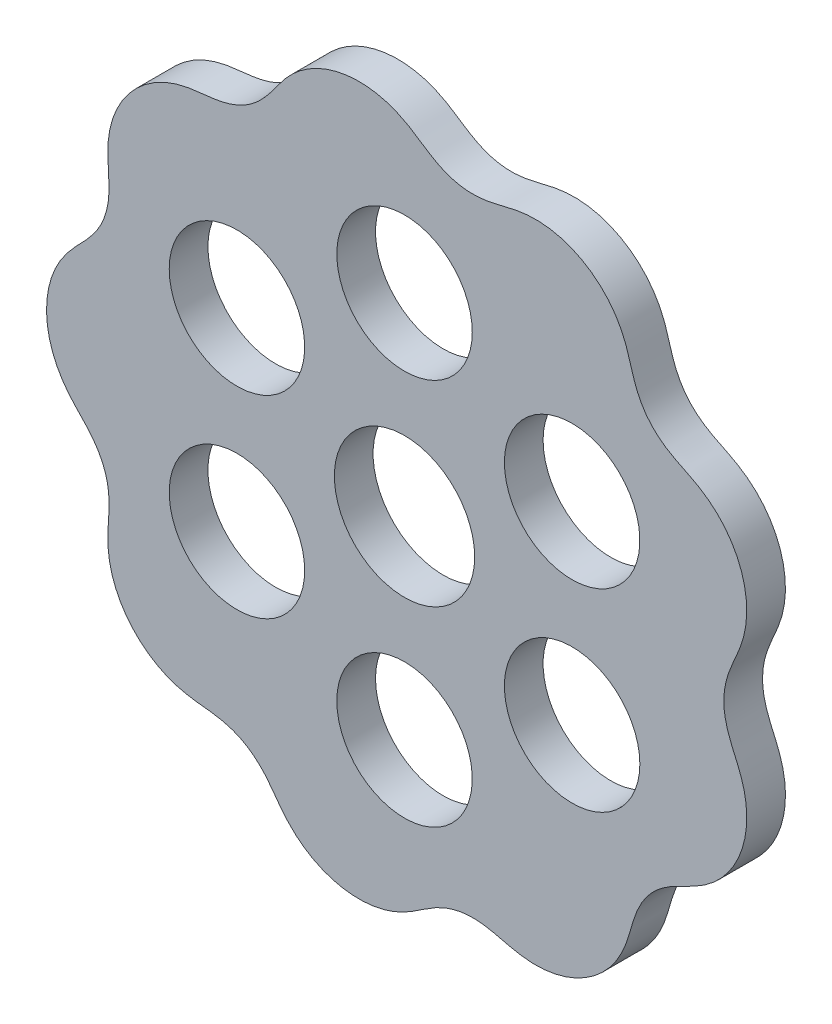
from build123d import *

# Parameters (mm, degrees)
BOSS_EXTRUDE1_DEPTH = 4
SKETCH3_R           = 7.25
CUT_EXTRUDE1_DEPTH  = 5.0000001
SKETCH4_R           = 7
CUT_EXTRUDE2_DEPTH  = 5.0000001
CIRPATTERN1_COUNT   = 6


with BuildPart() as part:
    # Sketch2 → Boss-Extrude1 (new body)
    with BuildSketch(Plane.XY):
        with BuildLine():
            add(Edge.make_bspline(
                [(33, 0), (33, 0.12553263), (33.006279573, 0.375087498), (33.033995401, 0.744846968), (33.078450452, 1.10445872), (33.137301626, 1.450009182), (33.20773948, 1.778739129), (33.286922785, 2.089062185), (33.372108042, 2.380504804), (33.460945471, 2.653467165), (33.551505246, 2.909016093), (33.642358629, 3.148634588), (33.732430922, 3.374068598), (33.821023827, 3.587149736), (33.907743377, 3.789679279), (33.992312739, 3.983430662), (34.074704021, 4.170007212), (34.154889985, 4.350925363), (34.232936694, 4.527528658), (34.30893687, 4.701027986), (34.382963112, 4.872499846), (34.455068419, 5.042906432), (34.525286112, 5.213090427), (34.593669893, 5.383774365), (34.660154697, 5.555616613), (34.724711071, 5.729167426), (34.78725947, 5.904896825), (34.847695164, 6.083213287), (34.905859859, 6.264456032), (34.961616233, 6.448896897), (35.014750379, 6.636767351), (35.065129988, 6.828218141), (35.112455854, 7.023393933), (35.156596015, 7.222343292), (35.197236986, 7.425123872), (35.234212467, 7.631709467), (35.267233912, 7.842071043), (35.296098781, 8.056118446), (35.320560731, 8.273747716), (35.340390552, 8.494814823), (35.355373574, 8.71914917), (35.365276709, 8.946558303), (35.369937718, 9.176820248), (35.369158767, 9.409695994), (35.362756857, 9.644921482), (35.350585299, 9.88221279), (35.332516501, 10.121280153), (35.30842634, 10.361808964), (35.278232355, 10.603480997), (35.241833438, 10.845956178), (35.199188137, 11.088899173), (35.150265015, 11.331959673), (35.095051004, 11.574786653), (35.033560116, 11.817023046), (34.965831637, 12.058316911), (34.89191067, 12.298311182), (34.811884594, 12.536657353), (34.725857402, 12.773012048), (34.633953155, 13.00703529), (34.536310687, 13.238394865), (34.433093942, 13.466773568), (34.324495961, 13.691865676), (34.210705098, 13.913372069), (34.091939112, 14.131010174), (33.968455375, 14.344530164), (33.840470585, 14.553668884), (33.708271364, 14.758217258), (33.572111879, 14.957953832), (33.432289899, 15.152709281), (33.28907516, 15.342302656), (33.142787006, 15.526615816), (32.993698434, 15.705513714), (32.842111494, 15.878902733), (32.688343005, 16.046737563), (32.532666931, 16.208957117), (32.375385617, 16.365566111), (32.216750424, 16.516548186), (32.057057619, 16.661974127), (31.89653629, 16.801884368), (31.73543292, 16.936383957), (31.573939877, 17.065574474), (31.412261582, 17.189628466), (31.25054194, 17.308708169), (31.08889597, 17.422997718), (30.927419369, 17.532743893), (30.7661561, 17.638205423), (30.605088205, 17.739645698), (30.444180041, 17.837405815), (30.283308185, 17.931819921), (30.122299104, 18.023269876), (29.960901455, 18.112161171), (29.79881075, 18.198969559), (29.635630397, 18.284206387), (29.470853606, 18.368379717), (29.303935278, 18.452171813), (29.134194665, 18.536226506), (28.96088611, 18.621344015), (28.783165292, 18.708381454), (28.600119766, 18.79835495), (28.410790633, 18.892406287), (28.214184873, 18.991828679), (28.009354406, 19.098102885), (27.795446663, 19.212893376), (27.571827908, 19.338058027), (27.338184991, 19.475602167), (27.094681821, 19.627609979), (26.842080553, 19.796098363), (26.581960792, 19.982936284), (26.316687995, 20.189467086), (26.04950029, 20.416355724), (25.78429141, 20.663258736), (25.52536734, 20.928681193), (25.27705575, 21.209966466), (25.043165446, 21.503351617), (24.82673082, 21.80443266), (24.62963072, 22.108484781), (24.452592408, 22.411019433), (24.295267263, 22.708123318), (24.156428544, 22.996734281), (24.034357478, 23.274749934), (23.92695169, 23.540955636), (23.832070987, 23.794931778), (23.747644698, 24.036888514), (23.671729145, 24.2674739), (23.602640108, 24.487650641), (23.538874232, 24.698537028), (23.479122238, 24.901320218), (23.422302364, 25.097205885), (23.367446548, 25.287342212), (23.313717452, 25.472796692), (23.260420936, 25.654557765), (23.206885664, 25.833488311), (23.152589274, 26.010376316), (23.097006271, 26.185884405), (23.039656754, 26.360585955), (22.980137739, 26.534966659), (22.918035808, 26.709409848), (22.85299235, 26.884232657), (22.784666989, 27.059673083), (22.712728622, 27.235906158), (22.636874162, 27.413033728), (22.556828501, 27.591109374), (22.472346263, 27.770143328), (22.383167271, 27.950087988), (22.289067228, 28.130851667), (22.18988343, 28.312331132), (22.085397272, 28.494339673), (21.975484654, 28.676716952), (21.860003652, 28.859238678), (21.738861055, 29.041678771), (21.611949853, 29.223770397), (21.479217881, 29.405241744), (21.34064873, 29.585831104), (21.196194455, 29.765206451), (21.04591332, 29.943105604), (20.88980923, 30.119179728), (20.727958651, 30.2931342), (20.560457769, 30.464662672), (20.387381765, 30.63342261), (20.208907804, 30.799144934), (20.025162875, 30.961498728), (19.836331685, 31.120191089), (19.642617356, 31.274938707), (19.444239603, 31.425464396), (19.24142684, 31.571500563), (19.034445368, 31.712806876), (18.823551595, 31.849137851), (18.609039053, 31.980279893), (18.391220098, 32.106054467), (18.170386866, 32.226243578), (17.946876072, 32.340719194), (17.721007109, 32.449317332), (17.493124574, 32.55193535), (17.263579357, 32.648478684), (17.032707701, 32.738873521), (16.800858484, 32.823042778), (16.568387013, 32.901001626), (16.335633408, 32.97270696), (16.102942132, 33.038206873), (15.870643449, 33.097505335), (15.639069555, 33.150694223), (15.408532012, 33.197837488), (15.179332611, 33.239059322), (14.951756992, 33.274455601), (14.726077141, 33.304171029), (14.50255218, 33.328383285), (14.28140279, 33.347241549), (14.062833672, 33.360937608), (13.847025657, 33.369683198), (13.634125034, 33.373697441), (13.424255309, 33.373152663), (13.217496676, 33.368331289), (13.013903121, 33.359426633), (12.813476772, 33.346698289), (12.616186384, 33.330347373), (12.421943643, 33.310626137), (12.230622713, 33.287749814), (12.042034408, 33.2619321), (11.855932295, 33.233395934), (11.672012527, 33.202300034), (11.489888098, 33.168863239), (11.309110788, 33.133221808), (11.12914045, 33.095525486), (10.949345622, 33.055924648), (10.769010509, 33.014493655), (10.587284669, 32.97139432), (10.403229236, 32.926672768), (10.215758299, 32.880474695), (10.023670132, 32.832907525), (9.825614052, 32.784190326), (9.620127588, 32.734519364), (9.405606899, 32.684318233), (9.180385781, 32.634055683), (8.942734121, 32.584508441), (8.690978854, 32.536640286), (8.423585585, 32.491820928), (8.139344037, 32.451732608), (7.837537509, 32.418462803), (7.518178574, 32.394370937), (7.182212158, 32.382069794), (6.831692591, 32.384124453), (6.469825315, 32.40279581), (6.100868235, 32.43969735), (5.729842354, 32.495554234), (5.362091269, 32.569970638), (5.002760027, 32.661475745), (4.656333738, 32.767708885), (4.326244593, 32.885655402), (4.014748663, 33.01212546), (3.722884215, 33.143982767), (3.450657043, 33.278471346), (3.197274119, 33.413363502), (2.961342887, 33.546938013), (2.741132669, 33.678005347), (2.534769756, 33.805863036), (2.340313653, 33.930113691), (2.155916926, 34.050679582), (1.97978911, 34.167605507), (1.81035742, 34.281153561), (1.64610722, 34.391530254), (1.485746686, 34.499067795), (1.328073849, 34.604025321), (1.172070856, 34.706711316), (1.0167655, 34.807297479), (0.861366885, 34.90601385), (0.705141565, 35.002988745), (0.547462441, 35.098316157), (0.387753578, 35.192018731), (0.225562033, 35.284145775), (0.060435418, 35.37460401), (-0.107944759, 35.463373103), (-0.27990324, 35.550307585), (-0.455686718, 35.635268929), (-0.635493509, 35.718099436), (-0.819468078, 35.798638174), (-1.007747803, 35.876617361), (-1.200380981, 35.951880493), (-1.397413404, 36.024159743), (-1.598840637, 36.093218833), (-1.804627734, 36.158797214), (-2.014699665, 36.220685281), (-2.228962735, 36.278602556), (-2.447293199, 36.332298816), (-2.669522355, 36.381554777), (-2.895478825, 36.426133844), (-3.12495136, 36.465795293), (-3.357713281, 36.500342206), (-3.593512378, 36.529568098), (-3.832085586, 36.553280072), (-4.073144064, 36.571330415), (-4.316389504, 36.583540636), (-4.561503139, 36.58981522), (-4.808159179, 36.589997725), (-5.05602004, 36.584030666), (-5.304745639, 36.571821792), (-5.55398056, 36.553317168), (-5.803372228, 36.528530698), (-6.05255323, 36.497395416), (-6.301176621, 36.459985103), (-6.548878869, 36.416313902), (-6.795306375, 36.36644189), (-7.040103302, 36.310448217), (-7.282937638, 36.248460906), (-7.523468116, 36.180592058), (-7.761369437, 36.106995698), (-7.996327399, 36.027837009), (-8.228045687, 35.943306116), (-8.456228068, 35.853574638), (-8.680624402, 35.758902333), (-8.900969343, 35.659493323), (-9.117051337, 35.555624685), (-9.328630414, 35.447502553), (-9.53554474, 35.335437686), (-9.737614247, 35.219680536), (-9.934696507, 35.10051126), (-10.126676072, 34.978216112), (-10.313469587, 34.85308499), (-10.495003377, 34.725374798), (-10.671246701, 34.595376714), (-10.842191396, 34.463362613), (-11.007848927, 34.329578741), (-11.168279118, 34.194277415), (-11.323553437, 34.057668157), (-11.473801436, 33.91998689), (-11.619147449, 33.781392469), (-11.759780224, 33.642058178), (-11.895892682, 33.502086963), (-12.027748191, 33.36158237), (-12.155627851, 33.220588347), (-12.279843512, 33.079100443), (-12.40074852, 32.937060716), (-12.518775983, 32.794387337), (-12.634348443, 32.65088173), (-12.747982513, 32.506321904), (-12.860248078, 32.360409923), (-12.971768683, 32.212758831), (-13.083258312, 32.062921411), (-13.195524915, 31.910366036), (-13.309434405, 31.754465831), (-13.426015888, 31.59456092), (-13.546405432, 31.429919557), (-13.671913564, 31.259804349), (-13.80395207, 31.083438316), (-13.944195046, 30.900184725), (-14.09437861, 30.709454235), (-14.256474792, 30.510968142), (-14.432500811, 30.304757556), (-14.624473994, 30.091342224), (-14.834275827, 29.871846128), (-15.063442767, 29.648121291), (-15.312902911, 29.422748519), (-15.582734339, 29.199013838), (-15.87193629, 28.980703292), (-16.17830184, 28.771819444), (-16.498423318, 28.576106746), (-16.82797235, 28.396724854), (-17.162062224, 28.235864855), (-17.495716123, 28.094543466), (-17.824398986, 27.972738936), (-18.144306853, 27.869379129), (-18.452646045, 27.78278676), (-18.747634224, 27.71083948), (-19.028440133, 27.651283907), (-19.295037502, 27.601965904), (-19.54797623, 27.560811344), (-19.788246142, 27.52611313), (-20.017074741, 27.496304675), (-20.235826902, 27.470113207), (-20.445909806, 27.446501966), (-20.648683422, 27.424542518), (-20.845458218, 27.403547622), (-21.03742371, 27.382834469), (-21.225676907, 27.361906237), (-21.411186158, 27.340267622), (-21.594814861, 27.317512716), (-21.777309428, 27.29322938), (-21.95931799, 27.26711177), (-22.141382271, 27.238764203), (-22.323958694, 27.207903506), (-22.507421011, 27.174204157), (-22.692062096, 27.137381162), (-22.878102525, 27.097123208), (-23.065712958, 27.053198338), (-23.254986675, 27.005295249), (-23.445974561, 26.953173435), (-23.638667212, 26.896587351), (-23.833030141, 26.83533155), (-24.028963534, 26.769142066), (-24.226360386, 26.697865852), (-24.425057113, 26.62129727), (-24.624854807, 26.539253666), (-24.825558886, 26.451626762), (-25.026925123, 26.35827691), (-25.228683958, 26.259059679), (-25.430589419, 26.153954726), (-25.632335336, 26.042862107), (-25.833615294, 25.92574142), (-26.0341193, 25.802581057), (-26.233543124, 25.673406958), (-26.431541153, 25.53821912), (-26.62781068, 25.397099826), (-26.82199596, 25.250097064), (-27.013789417, 25.097337777), (-27.202861558, 24.938940242), (-27.3888961, 24.775041633), (-27.571577712, 24.605807751), (-27.750630187, 24.431449774), (-27.92571202, 24.252126909), (-28.09660786, 24.068126528), (-28.263012325, 23.879651592), (-28.424686188, 23.686973372), (-28.581397278, 23.490364625), (-28.732947845, 23.290127749), (-28.879122884, 23.086552287), (-29.019752326, 22.879954138), (-29.154682091, 22.670656575), (-29.283784708, 22.458988338), (-29.406948786, 22.245282024), (-29.524077695, 22.029873164), (-29.635134786, 21.813115696), (-29.740020278, 21.595323651), (-29.838780023, 21.376860898), (-29.931367136, 21.158035901), (-30.017828311, 20.93918341), (-30.09820864, 20.720620565), (-30.172603668, 20.502657172), (-30.241051484, 20.285566096), (-30.303699396, 20.069633832), (-30.36067499, 19.855117517), (-30.412140336, 19.642254736), (-30.458211434, 19.431240916), (-30.499120739, 19.222275113), (-30.53505128, 19.015502984), (-30.566197587, 18.811050125), (-30.592780242, 18.60900071), (-30.61504895, 18.409407417), (-30.633211587, 18.212270482), (-30.647506651, 18.017554056), (-30.658204539, 17.825166523), (-30.665543328, 17.634960056), (-30.669731076, 17.446727481), (-30.671072772, 17.260203406), (-30.669755693, 17.075043574), (-30.666040016, 16.890825451), (-30.66019299, 16.707044113), (-30.652382952, 16.523105571), (-30.642924718, 16.33831319), (-30.63201537, 16.151862591), (-30.619932186, 15.962836648), (-30.607000474, 15.770189413), (-30.593515421, 15.57275999), (-30.579917187, 15.36925468), (-30.566699455, 15.158265515), (-30.554493573, 14.938289101), (-30.54411994, 14.707759292), (-30.536582795, 14.465115689), (-30.533174557, 14.208873681), (-30.535454116, 13.937762288), (-30.545340477, 13.650875497), (-30.564962781, 13.347874511), (-30.596719402, 13.029186169), (-30.64293677, 12.696190041), (-30.705826297, 12.351349844), (-30.78705942, 11.998222902), (-30.887454754, 11.64127175), (-31.006897874, 11.285586148), (-31.144034446, 10.936340178), (-31.296557294, 10.598364954), (-31.461333004, 10.275646955), (-31.63480283, 9.971055392), (-31.813445486, 9.686256078), (-31.993969112, 9.42171803), (-32.17370262, 9.176990397), (-32.350529956, 8.950866823), (-32.523055742, 8.741721436), (-32.690365723, 8.547613155), (-32.852118238, 8.366589329), (-33.008244645, 8.196659853), (-33.159000039, 8.036000641), (-33.304741669, 7.882862299), (-33.445970247, 7.735707717), (-33.583203224, 7.593130406), (-33.716949226, 7.453876246), (-33.847704279, 7.316835707), (-33.975905062, 7.181017676), (-34.101939416, 7.045542693), (-34.226137486, 6.909643577), (-34.348775456, 6.772640813), (-34.470013858, 6.633892904), (-34.59004643, 6.49289732), (-34.708927798, 6.349156045), (-34.826701065, 6.202260425), (-34.943348705, 6.051843675), (-35.058819863, 5.897591268), (-35.17302367, 5.739234906), (-35.285824067, 5.576547056), (-35.397071647, 5.409342815), (-35.506572671, 5.23747215), (-35.614132546, 5.060831117), (-35.719531849, 4.87935002), (-35.822504679, 4.692967606), (-35.922840602, 4.501699623), (-36.020264628, 4.305562058), (-36.11449737, 4.104605054), (-36.205308381, 3.898928797), (-36.292400789, 3.688626935), (-36.375532514, 3.473846033), (-36.454447511, 3.254748979), (-36.528871497, 3.03151718), (-36.598609902, 2.804376675), (-36.663383603, 2.573543825), (-36.723014665, 2.339281009), (-36.777303065, 2.101857519), (-36.826013865, 1.861549948), (-36.869040999, 1.618675413), (-36.906206293, 1.373540455), (-36.937366471, 1.126474948), (-36.962429457, 0.877815117), (-36.981323653, 0.627911778), (-36.99393153, 0.377105433), (-37.00026675, 0.125763276), (-37.00026675, -0.125763276), (-36.99393153, -0.377105433), (-36.981323653, -0.627911778), (-36.962429457, -0.877815117), (-36.937366471, -1.126474948), (-36.906206293, -1.373540455), (-36.869040999, -1.618675413), (-36.826013865, -1.861549948), (-36.777303065, -2.101857519), (-36.723014665, -2.339281009), (-36.663383603, -2.573543825), (-36.598609902, -2.804376675), (-36.528871497, -3.03151718), (-36.454447511, -3.254748979), (-36.375532514, -3.473846033), (-36.292400789, -3.688626935), (-36.205308381, -3.898928797), (-36.11449737, -4.104605054), (-36.020264628, -4.305562058), (-35.922840602, -4.501699623), (-35.822504679, -4.692967606), (-35.719531849, -4.87935002), (-35.614132546, -5.060831117), (-35.506572671, -5.23747215), (-35.397071647, -5.409342815), (-35.285824067, -5.576547056), (-35.17302367, -5.739234906), (-35.058819863, -5.897591268), (-34.943348705, -6.051843675), (-34.826701065, -6.202260425), (-34.708927798, -6.349156045), (-34.59004643, -6.49289732), (-34.470013858, -6.633892904), (-34.348775456, -6.772640813), (-34.226137486, -6.909643577), (-34.101939416, -7.045542693), (-33.975905062, -7.181017676), (-33.847704279, -7.316835707), (-33.716949226, -7.453876246), (-33.583203224, -7.593130406), (-33.445970247, -7.735707717), (-33.304741669, -7.882862299), (-33.159000039, -8.036000641), (-33.008244645, -8.196659853), (-32.852118238, -8.366589329), (-32.690365723, -8.547613155), (-32.523055742, -8.741721436), (-32.350529956, -8.950866823), (-32.17370262, -9.176990397), (-31.993969112, -9.42171803), (-31.813445486, -9.686256078), (-31.63480283, -9.971055392), (-31.461333004, -10.275646955), (-31.296557294, -10.598364954), (-31.144034446, -10.936340178), (-31.006897874, -11.285586148), (-30.887454754, -11.64127175), (-30.78705942, -11.998222902), (-30.705826297, -12.351349844), (-30.64293677, -12.696190041), (-30.596719402, -13.029186169), (-30.564962781, -13.347874511), (-30.545340477, -13.650875497), (-30.535454116, -13.937762288), (-30.533174557, -14.208873681), (-30.536582795, -14.465115689), (-30.54411994, -14.707759292), (-30.554493573, -14.938289101), (-30.566699455, -15.158265515), (-30.579917187, -15.36925468), (-30.593515421, -15.57275999), (-30.607000474, -15.770189413), (-30.619932186, -15.962836648), (-30.63201537, -16.151862591), (-30.642924718, -16.33831319), (-30.652382952, -16.523105571), (-30.66019299, -16.707044113), (-30.666040016, -16.890825451), (-30.669755693, -17.075043574), (-30.671072772, -17.260203406), (-30.669731076, -17.446727481), (-30.665543328, -17.634960056), (-30.658204539, -17.825166523), (-30.647506651, -18.017554056), (-30.633211587, -18.212270482), (-30.61504895, -18.409407417), (-30.592780242, -18.60900071), (-30.566197587, -18.811050125), (-30.53505128, -19.015502984), (-30.499120739, -19.222275113), (-30.458211434, -19.431240916), (-30.412140336, -19.642254736), (-30.36067499, -19.855117517), (-30.303699396, -20.069633832), (-30.241051484, -20.285566096), (-30.172603668, -20.502657172), (-30.09820864, -20.720620565), (-30.017828311, -20.93918341), (-29.931367136, -21.158035901), (-29.838780023, -21.376860898), (-29.740020278, -21.595323651), (-29.635134786, -21.813115696), (-29.524077695, -22.029873164), (-29.406948786, -22.245282024), (-29.283784708, -22.458988338), (-29.154682091, -22.670656575), (-29.019752326, -22.879954138), (-28.879122884, -23.086552287), (-28.732947845, -23.290127749), (-28.581397278, -23.490364625), (-28.424686188, -23.686973372), (-28.263012325, -23.879651592), (-28.09660786, -24.068126528), (-27.92571202, -24.252126909), (-27.750630187, -24.431449774), (-27.571577712, -24.605807751), (-27.3888961, -24.775041633), (-27.202861558, -24.938940242), (-27.013789417, -25.097337777), (-26.82199596, -25.250097064), (-26.62781068, -25.397099826), (-26.431541153, -25.53821912), (-26.233543124, -25.673406958), (-26.0341193, -25.802581057), (-25.833615294, -25.92574142), (-25.632335336, -26.042862107), (-25.430589419, -26.153954726), (-25.228683958, -26.259059679), (-25.026925123, -26.35827691), (-24.825558886, -26.451626762), (-24.624854807, -26.539253666), (-24.425057113, -26.62129727), (-24.226360386, -26.697865852), (-24.028963534, -26.769142066), (-23.833030141, -26.83533155), (-23.638667212, -26.896587351), (-23.445974561, -26.953173435), (-23.254986675, -27.005295249), (-23.065712958, -27.053198338), (-22.878102525, -27.097123208), (-22.692062096, -27.137381162), (-22.507421011, -27.174204157), (-22.323958694, -27.207903506), (-22.141382271, -27.238764203), (-21.95931799, -27.26711177), (-21.777309428, -27.29322938), (-21.594814861, -27.317512716), (-21.411186158, -27.340267622), (-21.225676907, -27.361906237), (-21.03742371, -27.382834469), (-20.845458218, -27.403547622), (-20.648683422, -27.424542518), (-20.445909806, -27.446501966), (-20.235826902, -27.470113207), (-20.017074741, -27.496304675), (-19.788246142, -27.52611313), (-19.54797623, -27.560811344), (-19.295037502, -27.601965904), (-19.028440133, -27.651283907), (-18.747634224, -27.71083948), (-18.452646045, -27.78278676), (-18.144306853, -27.869379129), (-17.824398986, -27.972738936), (-17.495716123, -28.094543466), (-17.162062224, -28.235864855), (-16.82797235, -28.396724854), (-16.498423318, -28.576106746), (-16.17830184, -28.771819444), (-15.87193629, -28.980703292), (-15.582734339, -29.199013838), (-15.312902911, -29.422748519), (-15.063442767, -29.648121291), (-14.834275827, -29.871846128), (-14.624473994, -30.091342224), (-14.432500811, -30.304757556), (-14.256474792, -30.510968142), (-14.09437861, -30.709454235), (-13.944195046, -30.900184725), (-13.80395207, -31.083438316), (-13.671913564, -31.259804349), (-13.546405432, -31.429919557), (-13.426015888, -31.59456092), (-13.309434405, -31.754465831), (-13.195524915, -31.910366036), (-13.083258312, -32.062921411), (-12.971768683, -32.212758831), (-12.860248078, -32.360409923), (-12.747982513, -32.506321904), (-12.634348443, -32.65088173), (-12.518775983, -32.794387337), (-12.40074852, -32.937060716), (-12.279843512, -33.079100443), (-12.155627851, -33.220588347), (-12.027748191, -33.36158237), (-11.895892682, -33.502086963), (-11.759780224, -33.642058178), (-11.619147449, -33.781392469), (-11.473801436, -33.91998689), (-11.323553437, -34.057668157), (-11.168279118, -34.194277415), (-11.007848927, -34.329578741), (-10.842191396, -34.463362613), (-10.671246701, -34.595376714), (-10.495003377, -34.725374798), (-10.313469587, -34.85308499), (-10.126676072, -34.978216112), (-9.934696507, -35.10051126), (-9.737614247, -35.219680536), (-9.53554474, -35.335437686), (-9.328630414, -35.447502553), (-9.117051337, -35.555624685), (-8.900969343, -35.659493323), (-8.680624402, -35.758902333), (-8.456228068, -35.853574638), (-8.228045687, -35.943306116), (-7.996327399, -36.027837009), (-7.761369437, -36.106995698), (-7.523468116, -36.180592058), (-7.282937638, -36.248460906), (-7.040103302, -36.310448217), (-6.795306375, -36.36644189), (-6.548878869, -36.416313902), (-6.301176621, -36.459985103), (-6.05255323, -36.497395416), (-5.803372228, -36.528530698), (-5.55398056, -36.553317168), (-5.304745639, -36.571821792), (-5.05602004, -36.584030666), (-4.808159179, -36.589997725), (-4.561503139, -36.58981522), (-4.316389504, -36.583540636), (-4.073144064, -36.571330415), (-3.832085586, -36.553280072), (-3.593512378, -36.529568098), (-3.357713281, -36.500342206), (-3.12495136, -36.465795293), (-2.895478825, -36.426133844), (-2.669522355, -36.381554777), (-2.447293199, -36.332298816), (-2.228962735, -36.278602556), (-2.014699665, -36.220685281), (-1.804627734, -36.158797214), (-1.598840637, -36.093218833), (-1.397413404, -36.024159743), (-1.200380981, -35.951880493), (-1.007747803, -35.876617361), (-0.819468078, -35.798638174), (-0.635493509, -35.718099436), (-0.455686718, -35.635268929), (-0.27990324, -35.550307585), (-0.107944759, -35.463373103), (0.060435418, -35.37460401), (0.225562033, -35.284145775), (0.387753578, -35.192018731), (0.547462441, -35.098316157), (0.705141565, -35.002988745), (0.861366885, -34.90601385), (1.0167655, -34.807297479), (1.172070856, -34.706711316), (1.328073849, -34.604025321), (1.485746686, -34.499067795), (1.64610722, -34.391530254), (1.81035742, -34.281153561), (1.97978911, -34.167605507), (2.155916926, -34.050679582), (2.340313653, -33.930113691), (2.534769756, -33.805863036), (2.741132669, -33.678005347), (2.961342887, -33.546938013), (3.197274119, -33.413363502), (3.450657043, -33.278471346), (3.722884215, -33.143982767), (4.014748663, -33.01212546), (4.326244593, -32.885655402), (4.656333738, -32.767708885), (5.002760027, -32.661475745), (5.362091269, -32.569970638), (5.729842354, -32.495554234), (6.100868235, -32.43969735), (6.469825315, -32.40279581), (6.831692591, -32.384124453), (7.182212158, -32.382069794), (7.518178574, -32.394370937), (7.837537509, -32.418462803), (8.139344037, -32.451732608), (8.423585585, -32.491820928), (8.690978854, -32.536640286), (8.942734121, -32.584508441), (9.180385781, -32.634055683), (9.405606899, -32.684318233), (9.620127588, -32.734519364), (9.825614052, -32.784190326), (10.023670132, -32.832907525), (10.215758299, -32.880474695), (10.403229236, -32.926672768), (10.587284669, -32.97139432), (10.769010509, -33.014493655), (10.949345622, -33.055924648), (11.12914045, -33.095525486), (11.309110788, -33.133221808), (11.489888098, -33.168863239), (11.672012527, -33.202300034), (11.855932295, -33.233395934), (12.042034408, -33.2619321), (12.230622713, -33.287749814), (12.421943643, -33.310626137), (12.616186384, -33.330347373), (12.813476772, -33.346698289), (13.013903121, -33.359426633), (13.217496676, -33.368331289), (13.424255309, -33.373152663), (13.634125034, -33.373697441), (13.847025657, -33.369683198), (14.062833672, -33.360937608), (14.28140279, -33.347241549), (14.50255218, -33.328383285), (14.726077141, -33.304171029), (14.951756992, -33.274455601), (15.179332611, -33.239059322), (15.408532012, -33.197837488), (15.639069555, -33.150694223), (15.870643449, -33.097505335), (16.102942132, -33.038206873), (16.335633408, -32.97270696), (16.568387013, -32.901001626), (16.800858484, -32.823042778), (17.032707701, -32.738873521), (17.263579357, -32.648478684), (17.493124574, -32.55193535), (17.721007109, -32.449317332), (17.946876072, -32.340719194), (18.170386866, -32.226243578), (18.391220098, -32.106054467), (18.609039053, -31.980279893), (18.823551595, -31.849137851), (19.034445368, -31.712806876), (19.24142684, -31.571500563), (19.444239603, -31.425464396), (19.642617356, -31.274938707), (19.836331685, -31.120191089), (20.025162875, -30.961498728), (20.208907804, -30.799144934), (20.387381765, -30.63342261), (20.560457769, -30.464662672), (20.727958651, -30.2931342), (20.88980923, -30.119179728), (21.04591332, -29.943105604), (21.196194455, -29.765206451), (21.34064873, -29.585831104), (21.479217881, -29.405241744), (21.611949853, -29.223770397), (21.738861055, -29.041678771), (21.860003652, -28.859238678), (21.975484654, -28.676716952), (22.085397272, -28.494339673), (22.18988343, -28.312331132), (22.289067228, -28.130851667), (22.383167271, -27.950087988), (22.472346263, -27.770143328), (22.556828501, -27.591109374), (22.636874162, -27.413033728), (22.712728622, -27.235906158), (22.784666989, -27.059673083), (22.85299235, -26.884232657), (22.918035808, -26.709409848), (22.980137739, -26.534966659), (23.039656754, -26.360585955), (23.097006271, -26.185884405), (23.152589274, -26.010376316), (23.206885664, -25.833488311), (23.260420936, -25.654557765), (23.313717452, -25.472796692), (23.367446548, -25.287342212), (23.422302364, -25.097205885), (23.479122238, -24.901320218), (23.538874232, -24.698537028), (23.602640108, -24.487650641), (23.671729145, -24.2674739), (23.747644698, -24.036888514), (23.832070987, -23.794931778), (23.92695169, -23.540955636), (24.034357478, -23.274749934), (24.156428544, -22.996734281), (24.295267263, -22.708123318), (24.452592408, -22.411019433), (24.62963072, -22.108484781), (24.82673082, -21.80443266), (25.043165446, -21.503351617), (25.27705575, -21.209966466), (25.52536734, -20.928681193), (25.78429141, -20.663258736), (26.04950029, -20.416355724), (26.316687995, -20.189467086), (26.581960792, -19.982936284), (26.842080553, -19.796098363), (27.094681821, -19.627609979), (27.338184991, -19.475602167), (27.571827908, -19.338058027), (27.795446663, -19.212893376), (28.009354406, -19.098102885), (28.214184873, -18.991828679), (28.410790633, -18.892406287), (28.600119766, -18.79835495), (28.783165292, -18.708381454), (28.96088611, -18.621344015), (29.134194665, -18.536226506), (29.303935278, -18.452171813), (29.470853606, -18.368379717), (29.635630397, -18.284206387), (29.79881075, -18.198969559), (29.960901455, -18.112161171), (30.122299104, -18.023269876), (30.283308185, -17.931819921), (30.444180041, -17.837405815), (30.605088205, -17.739645698), (30.7661561, -17.638205423), (30.927419369, -17.532743893), (31.08889597, -17.422997718), (31.25054194, -17.308708169), (31.412261582, -17.189628466), (31.573939877, -17.065574474), (31.73543292, -16.936383957), (31.89653629, -16.801884368), (32.057057619, -16.661974127), (32.216750424, -16.516548186), (32.375385617, -16.365566111), (32.532666931, -16.208957117), (32.688343005, -16.046737563), (32.842111494, -15.878902733), (32.993698434, -15.705513714), (33.142787006, -15.526615816), (33.28907516, -15.342302656), (33.432289899, -15.152709281), (33.572111879, -14.957953832), (33.708271364, -14.758217258), (33.840470585, -14.553668884), (33.968455375, -14.344530164), (34.091939112, -14.131010174), (34.210705098, -13.913372069), (34.324495961, -13.691865676), (34.433093942, -13.466773568), (34.536310687, -13.238394865), (34.633953155, -13.00703529), (34.725857402, -12.773012048), (34.811884594, -12.536657353), (34.89191067, -12.298311182), (34.965831637, -12.058316911), (35.033560116, -11.817023046), (35.095051004, -11.574786653), (35.150265015, -11.331959673), (35.199188137, -11.088899173), (35.241833438, -10.845956178), (35.278232355, -10.603480997), (35.30842634, -10.361808964), (35.332516501, -10.121280153), (35.350585299, -9.88221279), (35.362756857, -9.644921482), (35.369158767, -9.409695994), (35.369937718, -9.176820248), (35.365276709, -8.946558303), (35.355373574, -8.71914917), (35.340390552, -8.494814823), (35.320560731, -8.273747716), (35.296098781, -8.056118446), (35.267233912, -7.842071043), (35.234212467, -7.631709467), (35.197236986, -7.425123872), (35.156596015, -7.222343292), (35.112455854, -7.023393933), (35.065129988, -6.828218141), (35.014750379, -6.636767351), (34.961616233, -6.448896897), (34.905859859, -6.264456032), (34.847695164, -6.083213287), (34.78725947, -5.904896825), (34.724711071, -5.729167426), (34.660154697, -5.555616613), (34.593669893, -5.383774365), (34.525286112, -5.213090427), (34.455068419, -5.042906432), (34.382963112, -4.872499846), (34.30893687, -4.701027986), (34.232936694, -4.527528658), (34.154889985, -4.350925363), (34.074704021, -4.170007212), (33.992312739, -3.983430662), (33.907743377, -3.789679279), (33.821023827, -3.587149736), (33.732430922, -3.374068598), (33.642358629, -3.148634588), (33.551505246, -2.909016093), (33.460945471, -2.653467165), (33.372108042, -2.380504804), (33.286922785, -2.089062185), (33.20773948, -1.778739129), (33.137301626, -1.450009182), (33.078450452, -1.10445872), (33.033995401, -0.744846968), (33.006279573, -0.375087498), (33, -0.12553263), (33, 0)],
                knots=[0, 0, 0, 0, 0.001596431, 0.003173655, 0.004714116, 0.006203293, 0.007630405, 0.008988823, 0.010275714, 0.011491563, 0.012639279, 0.013723659, 0.014750673, 0.015726747, 0.016658586, 0.017552728, 0.018415492, 0.01925265, 0.020069634, 0.0208712, 0.021661735, 0.022445051, 0.023224546, 0.024003202, 0.02478361, 0.025567951, 0.026358213, 0.027155913, 0.027962504, 0.02877905, 0.02960646, 0.030445543, 0.03129678, 0.032160592, 0.033037255, 0.033926964, 0.034829628, 0.03574531, 0.036673768, 0.037614764, 0.038568021, 0.039533089, 0.040509568, 0.04149696, 0.042494679, 0.043502126, 0.044518646, 0.045543651, 0.046576313, 0.047615958, 0.048661828, 0.049713127, 0.050769019, 0.051828747, 0.052891415, 0.053956204, 0.055022311, 0.056088813, 0.057154895, 0.058219713, 0.059282369, 0.060342098, 0.061398011, 0.062449285, 0.063495155, 0.064534801, 0.065567464, 0.066592458, 0.067608978, 0.06861644, 0.069614164, 0.070601525, 0.071578032, 0.072543105, 0.073496338, 0.07443735, 0.075365812, 0.07628147, 0.077184184, 0.078073855, 0.078950493, 0.079814324, 0.08066557, 0.081504621, 0.082332054, 0.08314862, 0.083955194, 0.084752922, 0.085543149, 0.086327518, 0.087107919, 0.087886585, 0.08866607, 0.089449386, 0.090239895, 0.0910415, 0.091858437, 0.092695631, 0.093558374, 0.094452556, 0.095384364, 0.096360433, 0.097387415, 0.098471827, 0.099619548, 0.100835384, 0.102122276, 0.103480714, 0.104907811, 0.10639698, 0.107937444, 0.10951468, 0.111111098, 0.112707537, 0.114284766, 0.115825268, 0.117314392, 0.118741533, 0.120099923, 0.121386855, 0.122602661, 0.123750401, 0.124834798, 0.12586176, 0.126837849, 0.127769693, 0.128663835, 0.129526586, 0.130363774, 0.131180734, 0.1319823, 0.132772843, 0.13355614, 0.134335643, 0.13511429, 0.135894708, 0.136679089, 0.137469289, 0.138267029, 0.139073591, 0.139890165, 0.140717605, 0.141556619, 0.14240786, 0.143271725, 0.144148366, 0.145038063, 0.145940748, 0.146856419, 0.147784883, 0.148725857, 0.149679125, 0.150644186, 0.151620687, 0.152608071, 0.153605799, 0.154613205, 0.155629771, 0.15665474, 0.157687411, 0.158727079, 0.159772965, 0.160824239, 0.161880145, 0.162939837, 0.164002526, 0.165067303, 0.166133419, 0.167199946, 0.168265997, 0.169330807, 0.170393515, 0.171453193, 0.172509129, 0.173560387, 0.174606279, 0.175645907, 0.176678604, 0.177703561, 0.17872012, 0.179727557, 0.180725253, 0.181712625, 0.182689144, 0.183654224, 0.18460747, 0.185548446, 0.186476898, 0.187392583, 0.188295254, 0.189184965, 0.190061641, 0.190925463, 0.191776689, 0.192615755, 0.193443171, 0.194259748, 0.195066296, 0.19586401, 0.196654269, 0.197438609, 0.198219019, 0.198997701, 0.199777203, 0.20056053, 0.201351037, 0.202152598, 0.202969559, 0.203806732, 0.204669482, 0.205563637, 0.206495486, 0.20747156, 0.208498527, 0.209582946, 0.210730689, 0.21194651, 0.213233396, 0.21459182, 0.216018937, 0.2175081, 0.219048559, 0.220625798, 0.222222226, 0.223818653, 0.22539587, 0.226936369, 0.228425516, 0.229852648, 0.231211066, 0.232497957, 0.233713793, 0.23486148, 0.23594589, 0.236972898, 0.23794894, 0.238880795, 0.239774948, 0.240637718, 0.241474893, 0.242291853, 0.243093419, 0.243883936, 0.244667231, 0.245446757, 0.246225422, 0.24700583, 0.247790163, 0.248580423, 0.249378145, 0.250184725, 0.251001253, 0.251828695, 0.252667752, 0.253518981, 0.25438282, 0.255259488, 0.256149181, 0.257051892, 0.257967534, 0.258895967, 0.259837015, 0.260790218, 0.26175532, 0.262731792, 0.263719193, 0.264716881, 0.26572434, 0.266740878, 0.267765847, 0.268798541, 0.269838201, 0.270884051, 0.271935335, 0.272991231, 0.274050967, 0.275113647, 0.276178433, 0.277244505, 0.278311048, 0.279377107, 0.280441918, 0.281504594, 0.28256432, 0.283620243, 0.284671511, 0.285717368, 0.286757027, 0.287789686, 0.288814668, 0.289831203, 0.290838669, 0.291836373, 0.292823765, 0.29380026, 0.294765323, 0.295718551, 0.29665956, 0.297588047, 0.298503698, 0.299406373, 0.300296048, 0.301172716, 0.302036575, 0.302887803, 0.303726867, 0.304554309, 0.305370839, 0.306177422, 0.306975162, 0.307765362, 0.308549731, 0.30933013, 0.310108798, 0.310888322, 0.311671623, 0.312462147, 0.313263695, 0.31408067, 0.314917863, 0.31578059, 0.316674774, 0.317606605, 0.318582663, 0.319609639, 0.320694066, 0.321841786, 0.323057623, 0.324344505, 0.325702942, 0.327130043, 0.328619183, 0.330159648, 0.331736913, 0.33333333, 0.334929764, 0.336507009, 0.338047476, 0.339536625, 0.340963758, 0.342322175, 0.343609063, 0.344824899, 0.34597259, 0.347057012, 0.348084019, 0.349060057, 0.349991909, 0.350886074, 0.351748825, 0.35258598, 0.353402977, 0.354204525, 0.354995038, 0.355778374, 0.356557861, 0.357336534, 0.35811693, 0.358901301, 0.359691515, 0.360489265, 0.361295821, 0.362112342, 0.362939809, 0.36377888, 0.364630121, 0.365493915, 0.366370591, 0.367260284, 0.368162982, 0.369078668, 0.37000711, 0.370948114, 0.371901336, 0.372866441, 0.373842917, 0.374830292, 0.375828007, 0.376835432, 0.377851991, 0.37887696, 0.379909669, 0.380949319, 0.381995167, 0.383046434, 0.384102371, 0.385162067, 0.386224742, 0.387289568, 0.388355633, 0.389422142, 0.390488236, 0.391553038, 0.392615728, 0.393675427, 0.394731321, 0.395782595, 0.396828464, 0.39786813, 0.398900804, 0.399925785, 0.400942313, 0.401949771, 0.402947507, 0.40393487, 0.404911336, 0.405876455, 0.406829691, 0.40777069, 0.408699155, 0.409614779, 0.41051749, 0.41140715, 0.412283841, 0.413147655, 0.413998906, 0.414837976, 0.415665427, 0.416481953, 0.417288532, 0.418086273, 0.4188765, 0.419660832, 0.42044123, 0.421219912, 0.421999405, 0.42278274, 0.423573263, 0.424374833, 0.425191783, 0.426028977, 0.426891708, 0.427785853, 0.428717709, 0.429693767, 0.430720763, 0.431805155, 0.432952883, 0.434168714, 0.435455637, 0.436814025, 0.438241143, 0.439730303, 0.44127079, 0.442848023, 0.444444468, 0.446040861, 0.447618105, 0.44915858, 0.45064775, 0.452074836, 0.45343327, 0.454720148, 0.455936002, 0.457083707, 0.458168108, 0.459195096, 0.460171172, 0.461103015, 0.461997153, 0.46285993, 0.463697105, 0.464514059, 0.465315628, 0.466106155, 0.466889458, 0.467668993, 0.468447643, 0.469228034, 0.47001239, 0.470802661, 0.471600376, 0.472406932, 0.473223491, 0.47405093, 0.474889991, 0.475741213, 0.476605062, 0.477481727, 0.478371385, 0.479274083, 0.480189765, 0.481118228, 0.482059233, 0.483012466, 0.483977522, 0.484954007, 0.485941389, 0.486939093, 0.487946549, 0.488963101, 0.489988057, 0.491020751, 0.492060413, 0.49310627, 0.494157553, 0.495213485, 0.496273157, 0.49733585, 0.498400639, 0.499466752, 0.500533248, 0.501599361, 0.50266415, 0.503726843, 0.504786515, 0.505842447, 0.50689373, 0.507939587, 0.508979249, 0.510011943, 0.511036899, 0.512053451, 0.513060907, 0.514058611, 0.515045993, 0.516022478, 0.516987534, 0.517940767, 0.518881772, 0.519810235, 0.520725917, 0.521628615, 0.522518273, 0.523394938, 0.524258787, 0.525110009, 0.52594907, 0.526776509, 0.527593068, 0.528399624, 0.529197339, 0.52998761, 0.530771966, 0.531552357, 0.532331007, 0.533110542, 0.533893845, 0.534684372, 0.535485941, 0.536302895, 0.53714007, 0.538002847, 0.538896985, 0.539828828, 0.540804904, 0.541831892, 0.542916293, 0.544063998, 0.545279852, 0.54656673, 0.547925164, 0.54935225, 0.55084142, 0.552381895, 0.553959139, 0.555555532, 0.557151977, 0.55872921, 0.560269697, 0.561758857, 0.563185975, 0.564544363, 0.565831286, 0.567047117, 0.568194845, 0.569279237, 0.570306233, 0.571282291, 0.572214147, 0.573108292, 0.573971023, 0.574808217, 0.575625167, 0.576426737, 0.57721726, 0.578000595, 0.578780088, 0.57955877, 0.580339168, 0.5811235, 0.581913727, 0.582711468, 0.583518047, 0.584334573, 0.585162024, 0.586001094, 0.586852345, 0.587716159, 0.58859285, 0.58948251, 0.590385221, 0.591300845, 0.59222931, 0.593170309, 0.594123545, 0.595088664, 0.59606513, 0.597052493, 0.598050229, 0.599057687, 0.600074215, 0.601099196, 0.60213187, 0.603171536, 0.604217405, 0.605268679, 0.606324573, 0.607384272, 0.608446962, 0.609511764, 0.610577858, 0.611644367, 0.612710432, 0.613775258, 0.614837933, 0.615897629, 0.616953566, 0.618004833, 0.619050681, 0.620090331, 0.62112304, 0.622148009, 0.623164568, 0.624171993, 0.625169708, 0.626157083, 0.627133559, 0.628098664, 0.629051886, 0.62999289, 0.630921332, 0.631837018, 0.632739716, 0.633629409, 0.634506085, 0.635369879, 0.63622112, 0.637060191, 0.637887658, 0.638704179, 0.639510735, 0.640308485, 0.641098699, 0.64188307, 0.642663466, 0.643442139, 0.644221626, 0.645004962, 0.645795475, 0.646597023, 0.64741402, 0.648251175, 0.649113926, 0.650008091, 0.650939943, 0.651915981, 0.652942988, 0.65402741, 0.655175101, 0.656390937, 0.657677825, 0.659036242, 0.660463375, 0.661952524, 0.663492991, 0.665070236, 0.66666667, 0.668263087, 0.669840352, 0.671380817, 0.672869957, 0.674297058, 0.675655495, 0.676942377, 0.678158214, 0.679305934, 0.680390361, 0.681417337, 0.682393395, 0.683325226, 0.68421941, 0.685082137, 0.68591933, 0.686736305, 0.687537853, 0.688328377, 0.689111678, 0.689891202, 0.69066987, 0.691450269, 0.692234638, 0.693024838, 0.693822578, 0.694629161, 0.695445691, 0.696273133, 0.697112197, 0.697963425, 0.698827284, 0.699703952, 0.700593627, 0.701496302, 0.702411953, 0.70334044, 0.704281449, 0.705234677, 0.70619974, 0.707176235, 0.708163627, 0.709161331, 0.710168797, 0.711185332, 0.712210314, 0.713242973, 0.714282632, 0.715328489, 0.716379757, 0.71743568, 0.718495406, 0.719558082, 0.720622893, 0.721688952, 0.722755495, 0.723821567, 0.724886353, 0.725949033, 0.727008769, 0.728064665, 0.729115949, 0.730161799, 0.731201459, 0.732234153, 0.733259122, 0.73427566, 0.735283119, 0.736280807, 0.737268208, 0.73824468, 0.739209782, 0.740162985, 0.741104033, 0.742032466, 0.742948108, 0.743850819, 0.744740512, 0.74561718, 0.746481019, 0.747332248, 0.748171305, 0.748998747, 0.749815275, 0.750621855, 0.751419577, 0.752209837, 0.75299417, 0.753774578, 0.754553243, 0.755332769, 0.756116064, 0.756906581, 0.757708147, 0.758525107, 0.759362282, 0.760225052, 0.761119205, 0.76205106, 0.763027102, 0.76405411, 0.76513852, 0.766286207, 0.767502043, 0.768788934, 0.770147352, 0.771574484, 0.773063631, 0.77460413, 0.776181347, 0.777777774, 0.779374202, 0.780951441, 0.7824919, 0.783981063, 0.78540818, 0.786766604, 0.78805349, 0.789269311, 0.790417054, 0.791501473, 0.79252844, 0.793504514, 0.794436363, 0.795330518, 0.796193268, 0.797030441, 0.797847402, 0.798648963, 0.79943947, 0.800222797, 0.801002299, 0.801780981, 0.802561391, 0.803345731, 0.80413599, 0.804933704, 0.805740252, 0.806556829, 0.807384245, 0.808223311, 0.809074537, 0.809938359, 0.810815035, 0.811704746, 0.812607417, 0.813523102, 0.814451554, 0.81539253, 0.816345776, 0.817310856, 0.818287375, 0.819274747, 0.820272443, 0.82127988, 0.822296439, 0.823321396, 0.824354093, 0.825393721, 0.826439613, 0.827490871, 0.828546807, 0.829606485, 0.830669193, 0.831734003, 0.832800054, 0.833866581, 0.834932697, 0.835997474, 0.837060163, 0.838119855, 0.839175761, 0.840227035, 0.841272921, 0.842312589, 0.84334526, 0.844370229, 0.845386795, 0.846394201, 0.847391929, 0.848379313, 0.849355814, 0.850320875, 0.851274143, 0.852215117, 0.853143581, 0.854059252, 0.854961937, 0.855851634, 0.856728275, 0.85759214, 0.858443381, 0.859282395, 0.860109835, 0.860926409, 0.861732971, 0.862530711, 0.863320911, 0.864105292, 0.86488571, 0.865664357, 0.86644386, 0.867227157, 0.8680177, 0.868819266, 0.869636226, 0.870473414, 0.871336165, 0.872230307, 0.873162151, 0.87413824, 0.875165202, 0.876249599, 0.877397339, 0.878613145, 0.879900077, 0.881258467, 0.882685608, 0.884174732, 0.885715234, 0.887292463, 0.888888902, 0.89048532, 0.892062556, 0.89360302, 0.895092189, 0.896519286, 0.897877724, 0.899164616, 0.900380452, 0.901528173, 0.902612585, 0.903639567, 0.904615636, 0.905547444, 0.906441626, 0.907304369, 0.908141563, 0.9089585, 0.909760105, 0.910550614, 0.91133393, 0.912113415, 0.912892081, 0.913672482, 0.914456851, 0.915247078, 0.916044806, 0.91685138, 0.917667946, 0.918495379, 0.91933443, 0.920185676, 0.921049507, 0.921926145, 0.922815816, 0.92371853, 0.924634188, 0.92556265, 0.926503662, 0.927456895, 0.928421968, 0.929398475, 0.930385836, 0.93138356, 0.932391022, 0.933407542, 0.934432536, 0.935465199, 0.936504845, 0.937550715, 0.938601989, 0.939657902, 0.940717631, 0.941780287, 0.942845105, 0.943911187, 0.944977689, 0.946043796, 0.947108585, 0.948171253, 0.949230981, 0.950286873, 0.951338172, 0.952384042, 0.953423687, 0.954456349, 0.955481354, 0.956497874, 0.957505321, 0.95850304, 0.959490432, 0.960466911, 0.961431979, 0.962385236, 0.963326232, 0.96425469, 0.965170372, 0.966073036, 0.966962745, 0.967839408, 0.96870322, 0.969554457, 0.97039354, 0.97122095, 0.972037496, 0.972844087, 0.973641787, 0.974432049, 0.97521639, 0.975996798, 0.976775454, 0.977554949, 0.978338265, 0.9791288, 0.979930366, 0.98074735, 0.981584508, 0.982447272, 0.983341414, 0.984273253, 0.985249327, 0.986276341, 0.987360721, 0.988508437, 0.989724286, 0.991011177, 0.992369595, 0.993796707, 0.995285884, 0.996826345, 0.998403569, 1, 1, 1, 1], degree=3))
        make_face()
    extrude(amount=BOSS_EXTRUDE1_DEPTH)

    # Sketch3 → Cut-Extrude1 (cut, through all)
    with BuildSketch(Plane.XY.offset(4)):
        Circle(SKETCH3_R)
    extrude(amount=-CUT_EXTRUDE1_DEPTH, mode=Mode.SUBTRACT)

    # Sketch4 → Cut-Extrude2 (cut, through all)
    with BuildSketch(Plane.XY.offset(4)):
        with Locations((0, 20)):
            Circle(SKETCH4_R)
    cut_extrude2 = extrude(amount=-CUT_EXTRUDE2_DEPTH, mode=Mode.SUBTRACT)

    # CirPattern1: Cut-Extrude2 ×6 about axis
    cirpattern1_axis = Axis((0, 0, 0), (0, 0, 1))
    for i in range(1, CIRPATTERN1_COUNT):
        add(cut_extrude2.rotate(cirpattern1_axis, i * 360 / CIRPATTERN1_COUNT), mode=Mode.SUBTRACT)


solid = part.part
